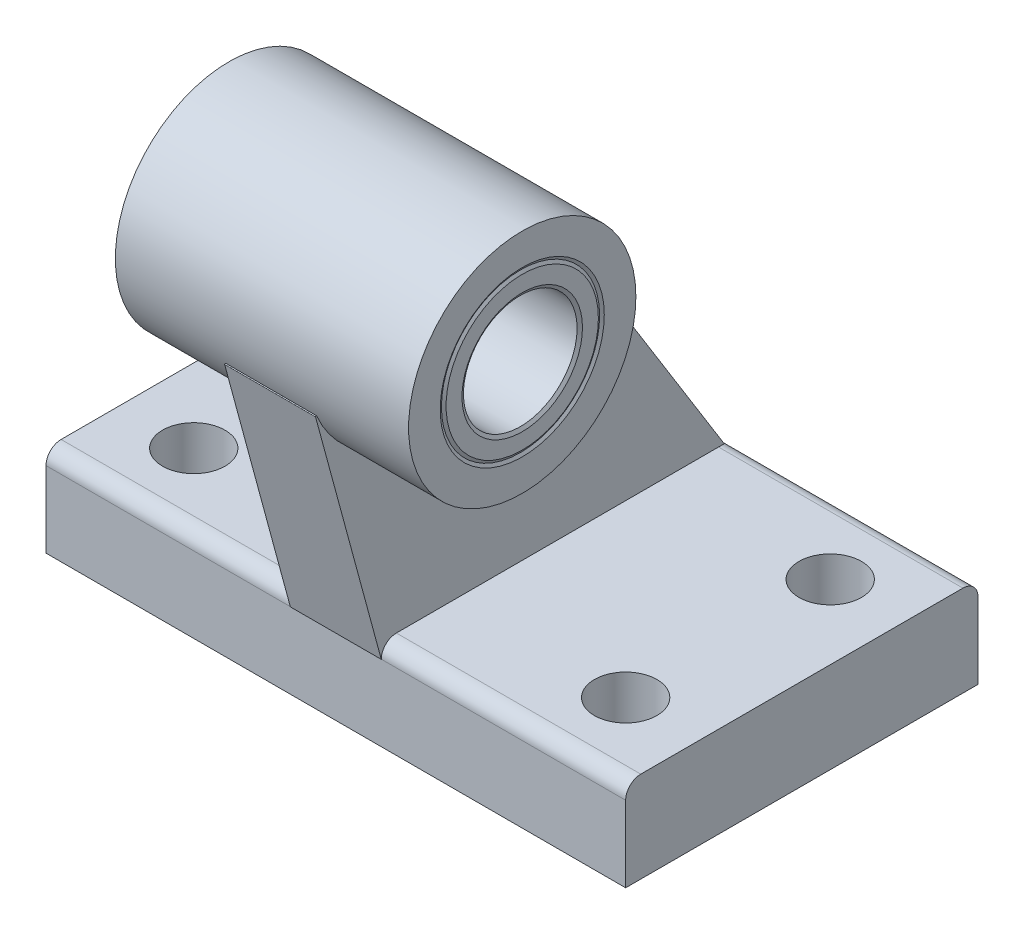
from build123d import *

# Parameters (mm, degrees)
BOSS_EXTRUDE1_DEPTH      = 25.5
BOSS_EXTRUDE1_DEPTH_BACK = 25.5
BOSS_EXTRUDE2_DEPTH      = 4
BOSS_EXTRUDE2_DEPTH_BACK = 4
BOSS_EXTRUDE3_DEPTH      = 12.9
BOSS_EXTRUDE3_DEPTH_BACK = 12.9
SKETCH3_R                = 10
SKETCH4_W                = 2.75
SKETCH4_H                = 8
SKETCH5_W                = 2.75
SKETCH5_H                = 8
SKETCH6_W                = 2.75
SKETCH6_H                = 8
SKETCH7_W                = 2.75
SKETCH7_H                = 8


with BuildPart() as part:
    # Sketch1 → Boss-Extrude1 (new, two sides: drawn at the far end of the back side and taken through both)
    with BuildSketch(Plane(origin=(0, 0, 0), x_dir=(0, 0, -1), z_dir=(1, 0, 0)).offset(-BOSS_EXTRUDE1_DEPTH_BACK)):
        with BuildLine():
            Line((-15.5, 6.672), (-15.5, 0))
            Line((-15.5, 0), (15.5, 0))
            Line((15.5, 0), (15.5, 6.672))
            ThreePointArc((15.5, 6.672), (15.111037805, 7.611037805), (14.172, 8))
            Line((14.172, 8), (-14.172, 8))
            ThreePointArc((-14.172, 8), (-15.111037805, 7.611037805), (-15.5, 6.672))
        make_face()
    extrude(amount=BOSS_EXTRUDE1_DEPTH + BOSS_EXTRUDE1_DEPTH_BACK)

    # Sketch2 → Boss-Extrude2 (add, two sides: drawn at the far end of the back side and taken through both)
    with BuildSketch(Plane(origin=(0, 0, 0), x_dir=(0, 0, -1), z_dir=(1, 0, 0)).offset(-BOSS_EXTRUDE2_DEPTH_BACK)):
        with BuildLine():
            Line((-21.283175656, 28.022230556), (-15.5, 6.656))
            ThreePointArc((-15.5, 6.656), (-15.106351514, 7.606351514), (-14.156, 8))
            Line((-14.156, 8), (14.675312578, 8))
            Line((14.675312578, 8), (-2.758705731, 36.074123248))
            ThreePointArc((-2.758705731, 36.074123248), (-2.824497754, 36.091976454), (-2.846947105, 36.027607565))
            ThreePointArc((-2.846947105, 36.027607565), (-8.013665194, 22.828896751), (-21.188967498, 28.055018845))
            ThreePointArc((-21.188967498, 28.055018845), (-21.251347415, 28.082515631), (-21.283175656, 28.022230556))
        make_face()
    extrude(amount=BOSS_EXTRUDE2_DEPTH + BOSS_EXTRUDE2_DEPTH_BACK)

    # Sketch3 → Boss-Extrude3 (add, two sides: drawn at the far end of the back side and taken through both)
    with BuildSketch(Plane(origin=(0, 0, 0), x_dir=(0, 0, -1), z_dir=(1, 0, 0)).offset(-BOSS_EXTRUDE3_DEPTH_BACK)):
        with Locations((-12, 32)):
            Circle(SKETCH3_R)
    extrude(amount=BOSS_EXTRUDE3_DEPTH + BOSS_EXTRUDE3_DEPTH_BACK)

    # Sketch4 → Cut-Revolve1 (revolve, cut)
    with BuildSketch(Plane.XY.offset(9)):
        with Locations((-20.375, 4)):
            Rectangle(SKETCH4_W, SKETCH4_H)
    revolve(axis=Axis((-19, 8, 9), (0, -1, 0)), mode=Mode.SUBTRACT)

    # Sketch5 → Cut-Revolve2 (revolve, cut)
    with BuildSketch(Plane.XY.offset(9)):
        with Locations((17.625, 4)):
            Rectangle(SKETCH5_W, SKETCH5_H)
    revolve(axis=Axis((19, 8, 9), (0, -1, 0)), mode=Mode.SUBTRACT)

    # Sketch6 → Cut-Revolve3 (revolve, cut)
    with BuildSketch(Plane.XY.offset(-9)):
        with Locations((-20.375, 4)):
            Rectangle(SKETCH6_W, SKETCH6_H)
    revolve(axis=Axis((-19, 8, -9), (0, -1, 0)), mode=Mode.SUBTRACT)

    # Sketch7 → Cut-Revolve4 (revolve, cut)
    with BuildSketch(Plane.XY.offset(-9)):
        with Locations((17.625, 4)):
            Rectangle(SKETCH7_W, SKETCH7_H)
    revolve(axis=Axis((19, 8, -9), (0, -1, 0)), mode=Mode.SUBTRACT)

    # Sketch8 → Cut-Revolve5 (revolve, cut)
    with BuildSketch(Plane.XY.offset(12)):
        Polygon((-12.9, 32), (-12.9, 39.22), (-12.611324865, 38.72), (12.611324865, 38.72), (12.9, 39.22), (12.9, 32), align=None)
    revolve(axis=Axis((12.9, 32, 12), (-1, 0, 0)), mode=Mode.SUBTRACT)

    # Sketch9 → Revolve1 (revolve)
    with BuildSketch(Plane.XY.offset(12)):
        Polygon((-12.9, 37.3), (-12.726794919, 37), (12.726794919, 37), (12.9, 37.3), (12.9, 38.7), (12.726794919, 39), (-12.726794919, 39), (-12.9, 38.7), align=None)
    revolve(axis=Axis((12.9, 32, 12), (-1, 0, 0)))


solid = part.part
